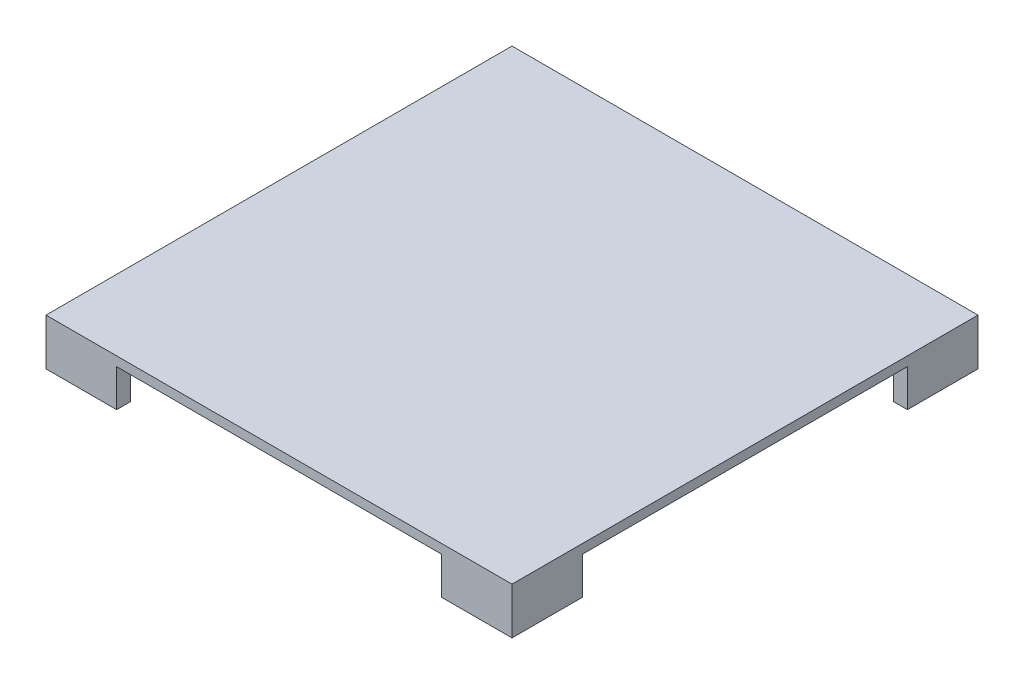
from build123d import *

# Parameters (mm, degrees)
SKETCH2_W           = 500
SKETCH2_H           = 500
BOSS_EXTRUDE1_DEPTH = 10
BOSS_EXTRUDE2_DEPTH = 40


with BuildPart() as part:
    # Sketch2 → Boss-Extrude1 (new body)
    with BuildSketch(Plane(origin=(0, 0, 0), x_dir=(1, 0, 0), z_dir=(0, 1, 0))):
        Rectangle(SKETCH2_W, SKETCH2_H)
    extrude(amount=BOSS_EXTRUDE1_DEPTH)

    # Sketch2_3 → Boss-Extrude2 (add)
    with BuildSketch(Plane(origin=(0, 0, 0), x_dir=(1, 0, 0), z_dir=(0, 1, 0))):
        Polygon((-250, -174.250613401), (-250, -250), (-174.250613401, -250), (-174.250613401, -235), (-235, -235), (-235, -174.250613401), align=None)
        Polygon((174.250613401, -235), (174.250613401, -250), (250, -250), (250, -174.250613401), (235, -174.250613401), (235, -235), align=None)
        Polygon((-250, 250), (-250, 174.250613401), (-235, 174.250613401), (-235, 235), (-174.250613401, 235), (-174.250613401, 250), align=None)
        Polygon((235, 174.250613401), (250, 174.250613401), (250, 250), (174.250613401, 250), (174.250613401, 235), (235, 235), align=None)
    extrude(amount=-BOSS_EXTRUDE2_DEPTH)


solid = part.part
